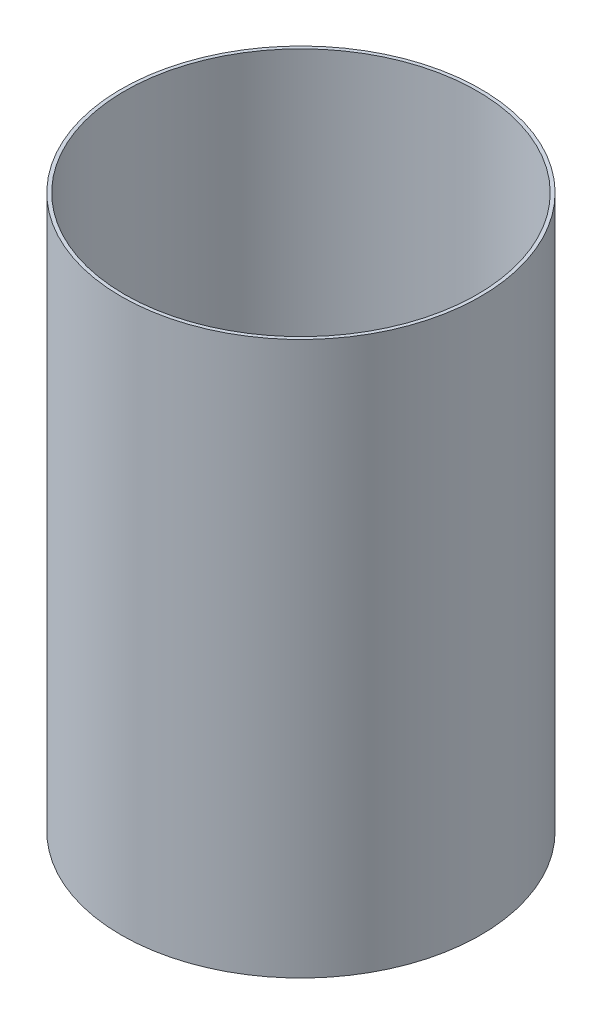
from build123d import *

# Parameters (mm, degrees)
SKETCH1_R           = 66.04
SKETCH1_R_2         = 64.77
BOSS_EXTRUDE1_DEPTH = 203.2


with BuildPart() as part:
    # Sketch1 → Boss-Extrude1 (new body)
    with BuildSketch(Plane(origin=(0, 0, 0), x_dir=(1, 0, 0), z_dir=(0, 1, 0))):
        Circle(SKETCH1_R)
        Circle(SKETCH1_R_2, mode=Mode.SUBTRACT)
    extrude(amount=BOSS_EXTRUDE1_DEPTH)


solid = part.part
